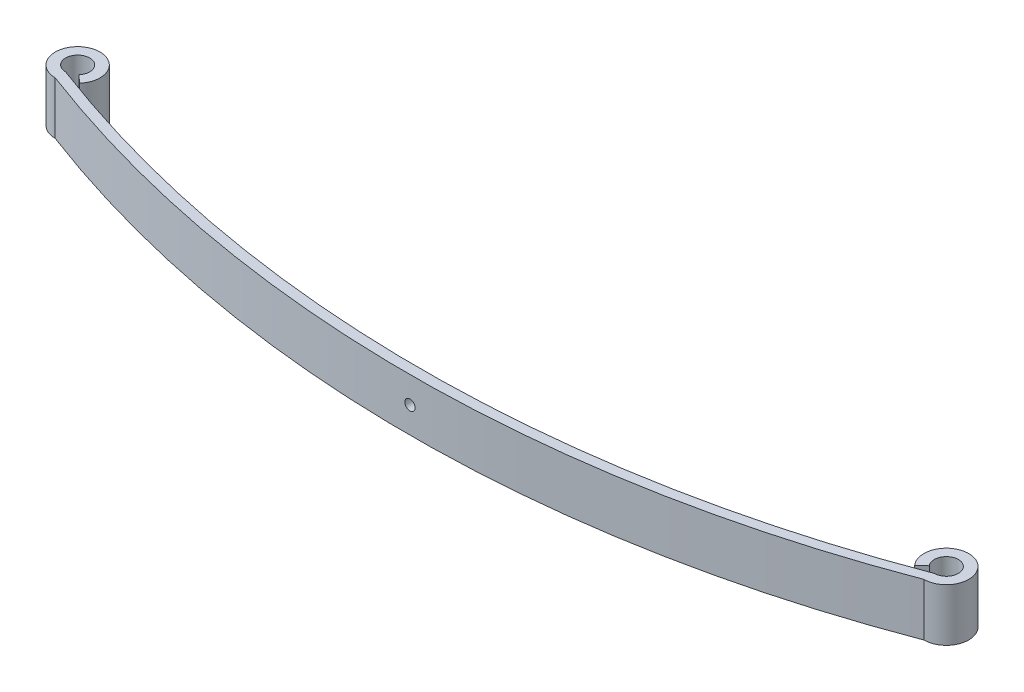
from build123d import *

# Parameters (mm, degrees)
BOSS_EXTRUDE3_DEPTH = 76.2
SKETCH5_R           = 7.5
CUT_EXTRUDE3_DEPTH  = 149


with BuildPart() as part:
    # Sketch1 → Boss-Extrude3 (new body)
    with BuildSketch(Plane(origin=(0, 0, 0), x_dir=(1, 0, 0), z_dir=(0, 1, 0))):
        with BuildLine():
            Line((-616.834962438, -11.529604763), (-605.550644545, -21.412123117))
            ThreePointArc((-605.550644545, -21.412123117), (-643.422534006, 29.598742869), (-630.001110861, -32.499999959))
            ThreePointArc((-630.001110861, -32.499999959), (0, -148), (630.001110861, -32.499999959))
            ThreePointArc((630.001110861, -32.499999959), (643.422534006, 29.598742869), (605.550644545, -21.412123117))
            Line((605.550644545, -21.412123117), (616.834962438, -11.529604763))
            ThreePointArc((616.834962438, -11.529604763), (637.227790694, 15.937661111), (630, -17.5))
            ThreePointArc((630, -17.5), (0, -133), (-630, -17.5))
            ThreePointArc((-630, -17.5), (-637.227790694, 15.937661111), (-616.834962438, -11.529604763))
        make_face()
    extrude(amount=BOSS_EXTRUDE3_DEPTH)

    # Sketch5 → Cut-Extrude3 (cut, through all)
    with BuildSketch(Plane.XY):
        with Locations((0, 38.1)):
            Circle(SKETCH5_R)
    extrude(amount=CUT_EXTRUDE3_DEPTH, mode=Mode.SUBTRACT)


solid = part.part
